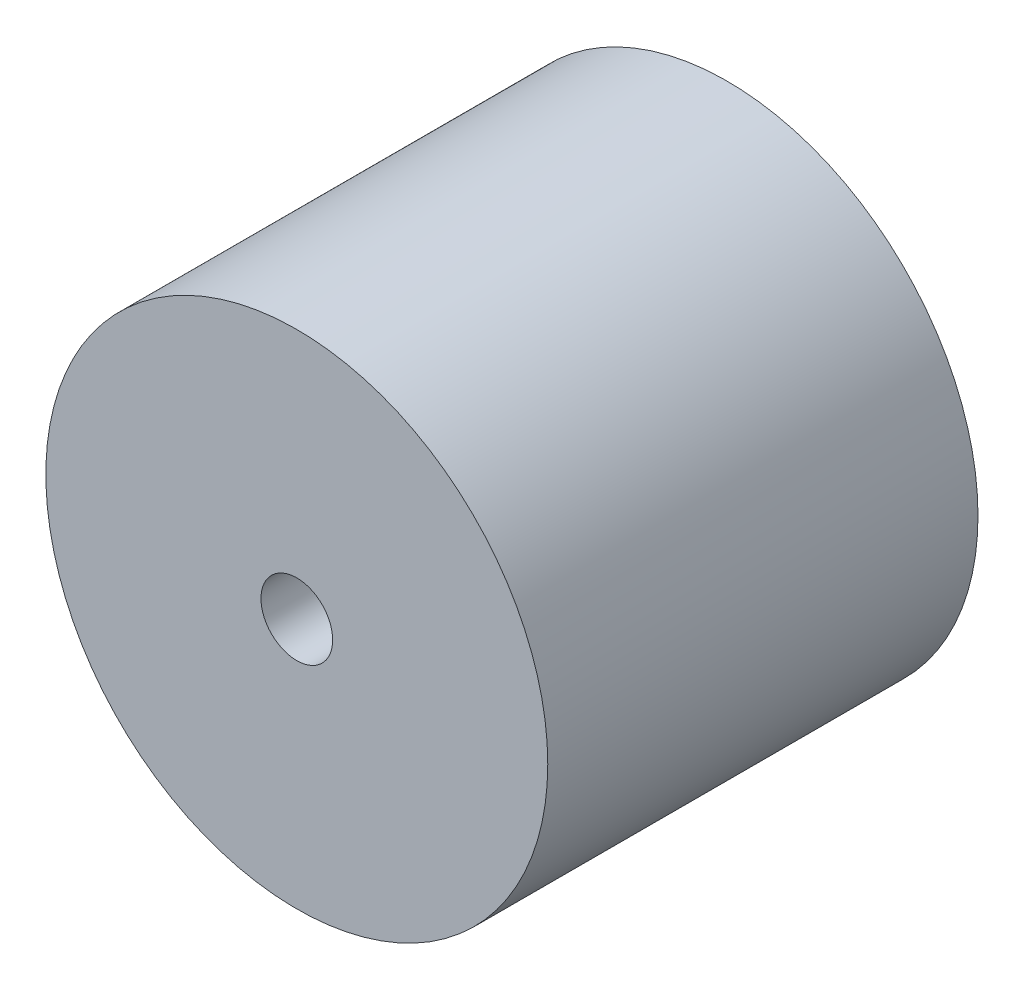
from build123d import *

# Parameters (mm, degrees)
ESQUISSE1_R             = 35
BOSS_EXTRU_1_DEPTH      = 60
ESQUISSE2_R             = 5
ENL_V_MAT_EXTRU_1_DEPTH = 60


with BuildPart() as part:
    # Esquisse1 → Boss.-Extru.1 (new body)
    with BuildSketch(Plane.XY):
        Circle(ESQUISSE1_R)
    extrude(amount=BOSS_EXTRU_1_DEPTH)

    # Esquisse2 → Enlèv. mat.-Extru.1 (cut)
    with BuildSketch(Plane.XY.offset(60)):
        Circle(ESQUISSE2_R)
    extrude(amount=-ENL_V_MAT_EXTRU_1_DEPTH, mode=Mode.SUBTRACT)


solid = part.part
